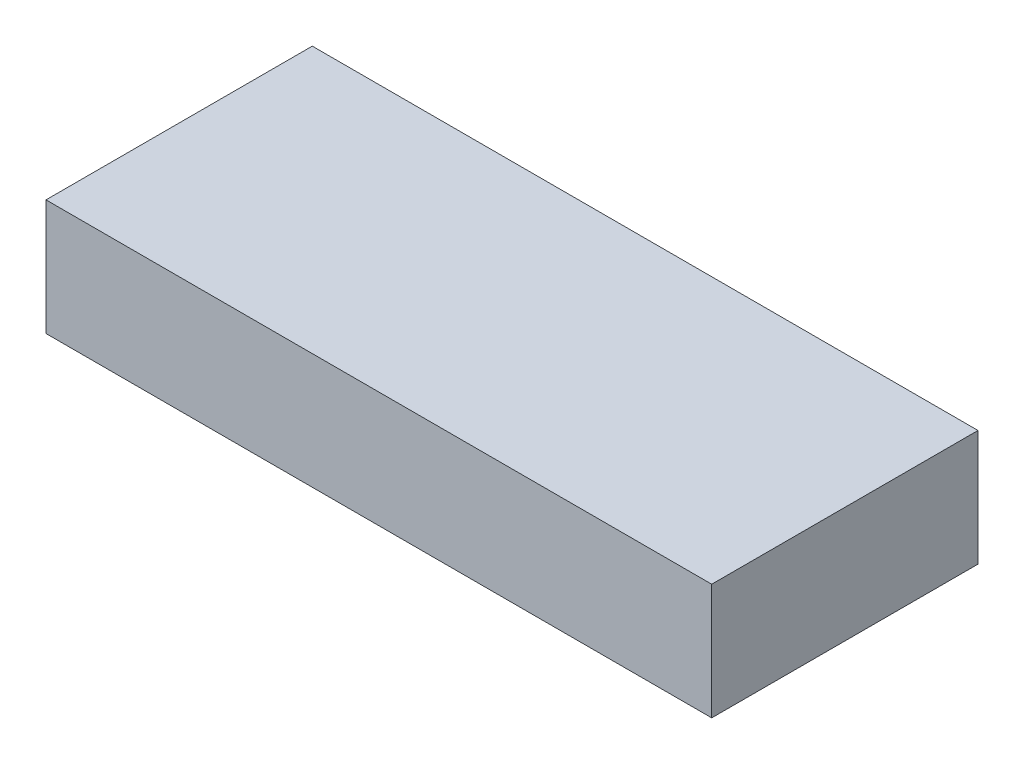
from build123d import *

# Parameters (mm, degrees)
SKETCH_1_W      = 115
SKETCH_1_H      = 46
EXTRUDE_1_DEPTH = 20


with BuildPart() as part:
    # 草图1 → 凸台-拉伸1 (new body)
    with BuildSketch(Plane(origin=(0, 0, 0), x_dir=(1, 0, 0), z_dir=(0, 1, 0))):
        Rectangle(SKETCH_1_W, SKETCH_1_H)
    extrude(amount=EXTRUDE_1_DEPTH)


solid = part.part
